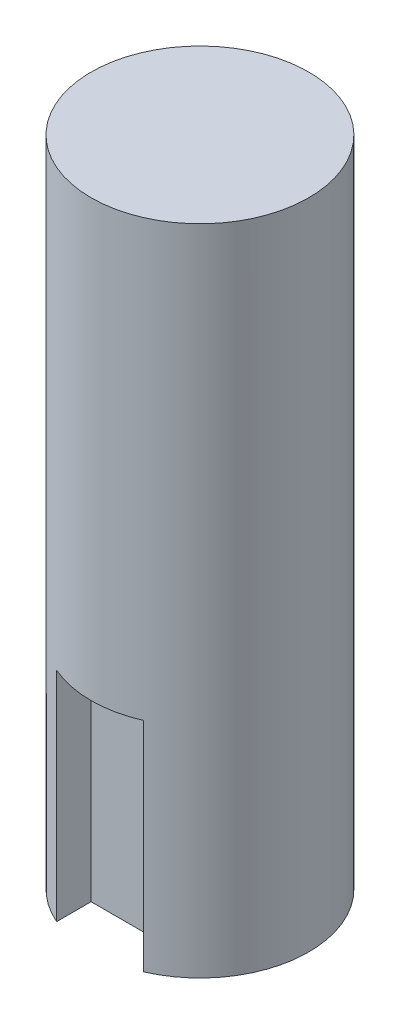
from build123d import *

# Parameters (mm, degrees)
SKETCH1_R           = 5
BOSS_EXTRUDE1_DEPTH = 30
CUT_EXTRUDE1_DEPTH  = 10


with BuildPart() as part:
    # Sketch1 → Boss-Extrude1 (new body)
    with BuildSketch(Plane(origin=(0, 0, 0), x_dir=(1, 0, 0), z_dir=(0, 1, 0))):
        Circle(SKETCH1_R)
    extrude(amount=BOSS_EXTRUDE1_DEPTH)

    # Sketch2 → Cut-Extrude1 (cut)
    with BuildSketch(Plane.XZ):
        with BuildLine():
            Line((-2, 3), (2, 3))
            Line((2, 3), (2, 4.582575695))
            ThreePointArc((2, 4.582575695), (0, 5), (-2, 4.582575695))
            Line((-2, 4.582575695), (-2, 3))
        make_face()
    extrude(amount=-CUT_EXTRUDE1_DEPTH, mode=Mode.SUBTRACT)


solid = part.part
